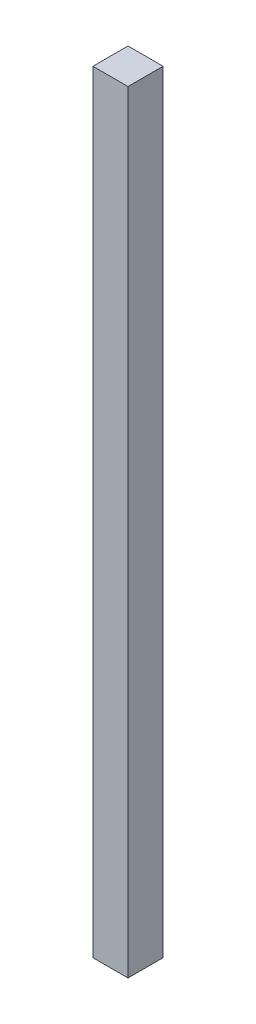
from build123d import *

# Parameters (mm, degrees)
ESQUISSE6_W        = 20
ESQUISSE6_H        = 20
BOSS_EXTRU_1_DEPTH = 440


with BuildPart() as part:
    # Esquisse6 → Boss.-Extru.1 (new body)
    with BuildSketch(Plane(origin=(0, 0, 0), x_dir=(1, 0, 0), z_dir=(0, 1, 0))):
        with Locations((-10, 10)):
            Rectangle(ESQUISSE6_W, ESQUISSE6_H)
    extrude(amount=BOSS_EXTRU_1_DEPTH)


solid = part.part
